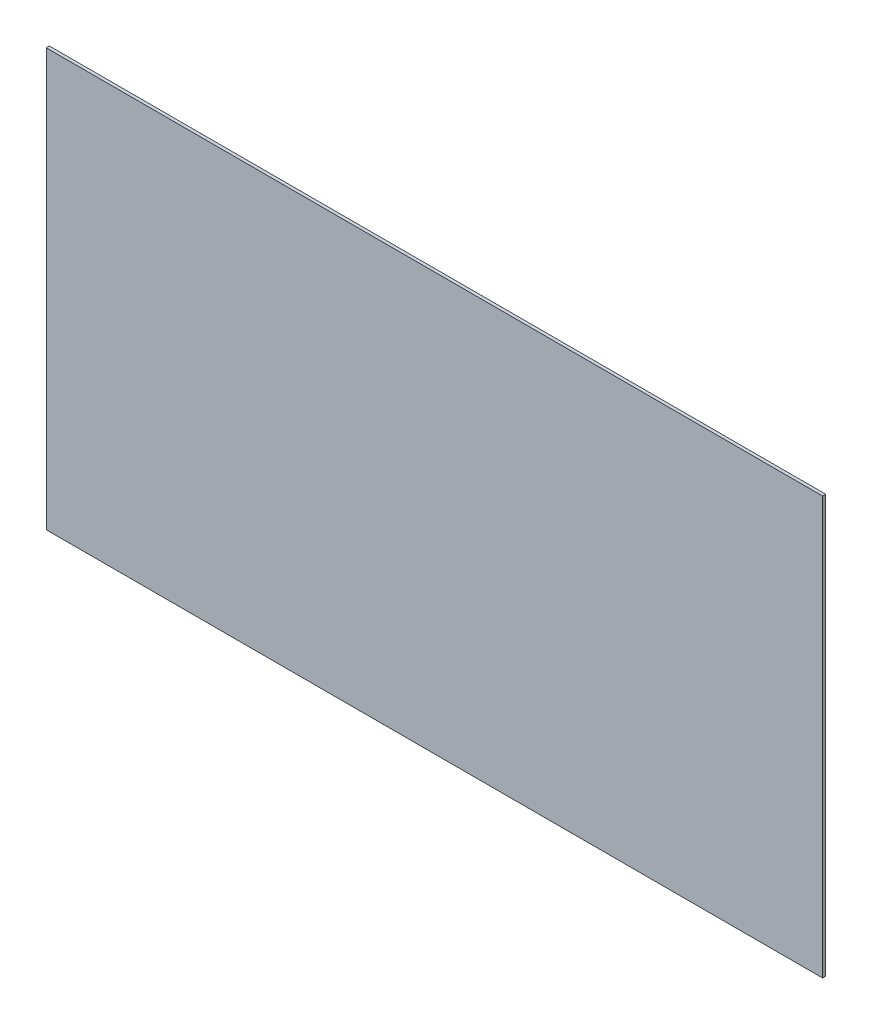
from build123d import *

# Parameters (mm, degrees)
SKETCH1_W      = 372
SKETCH1_H      = 200
EXTRUDE1_DEPTH = 1.5


with BuildPart() as part:
    # Sketch1 → Extrude1 (new body)
    with BuildSketch(Plane.XY):
        with Locations((186, 100)):
            Rectangle(SKETCH1_W, SKETCH1_H)
    extrude(amount=EXTRUDE1_DEPTH)


solid = part.part
